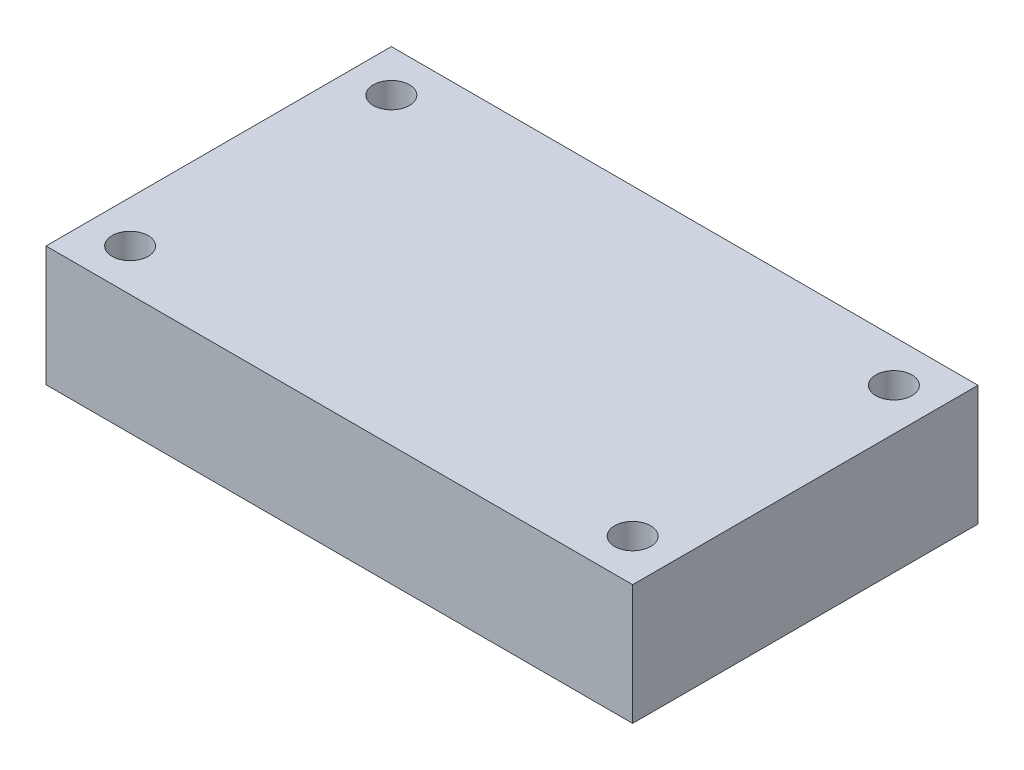
from build123d import *

# Parameters (mm, degrees)
SKETCH1_W           = 62
SKETCH1_H           = 36.5
BOSS_EXTRUDE1_DEPTH = 12.7
SKETCH2_R           = 1.905
CUT_EXTRUDE1_DEPTH  = 12.7


with BuildPart() as part:
    # Sketch1 → Boss-Extrude1 (new body)
    with BuildSketch(Plane(origin=(0, 0, 0), x_dir=(1, 0, 0), z_dir=(0, 1, 0))):
        Rectangle(SKETCH1_W, SKETCH1_H)
    extrude(amount=BOSS_EXTRUDE1_DEPTH)

    # Sketch2 → Cut-Extrude1 (cut)
    with BuildSketch(Plane(origin=(0, 12.7, 0), x_dir=(1, 0, 0), z_dir=(0, 1, 0))):
        with Locations((26.555, 13.805)):
            Circle(SKETCH2_R)
        with Locations((26.555, -13.805)):
            Circle(SKETCH2_R)
        with Locations((-26.555, 13.805)):
            Circle(SKETCH2_R)
        with Locations((-26.555, -13.805)):
            Circle(SKETCH2_R)
    extrude(amount=-CUT_EXTRUDE1_DEPTH, mode=Mode.SUBTRACT)


solid = part.part
